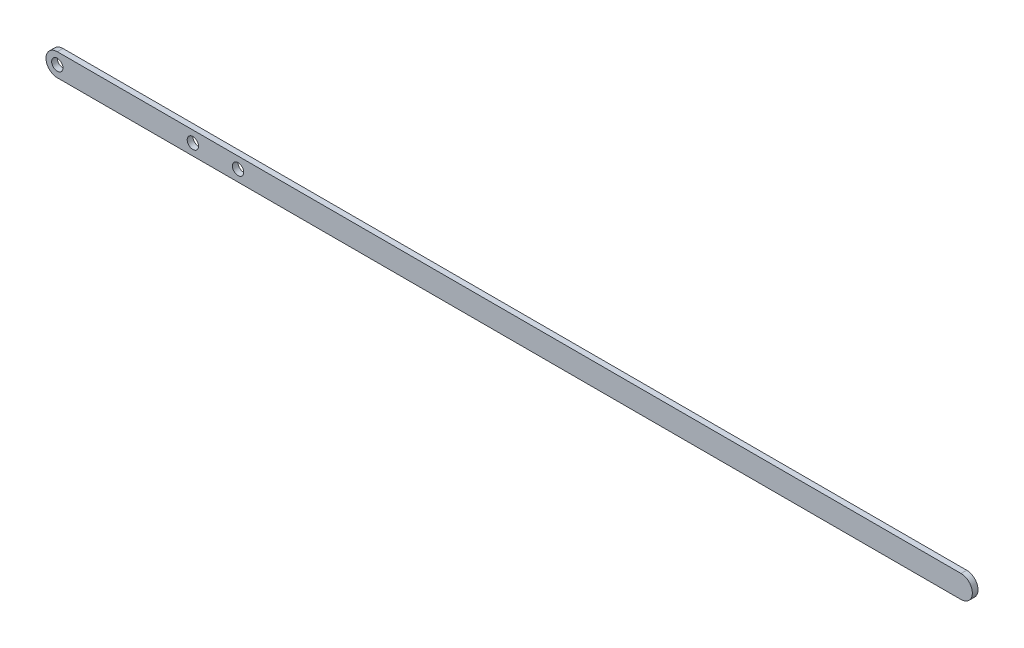
from build123d import *

# Parameters (mm, degrees)
SKETCH1_R           = 3.175
BOSS_EXTRUDE2_DEPTH = 3.175


with BuildPart() as part:
    # Sketch1 → Boss-Extrude2 (new body)
    with BuildSketch(Plane.XY):
        with BuildLine():
            Line((-254, 6.35), (254, 6.35))
            ThreePointArc((254, 6.35), (260.35, 0), (254, -6.35))
            Line((254, -6.35), (-254, -6.35))
            ThreePointArc((-254, -6.35), (-260.35, 0), (-254, 6.35))
        make_face()
        with Locations((-254, 0)):
            Circle(SKETCH1_R, mode=Mode.SUBTRACT)
        with Locations((-177.8, 0)):
            Circle(SKETCH1_R, mode=Mode.SUBTRACT)
        with Locations((-152.4, 0)):
            Circle(SKETCH1_R, mode=Mode.SUBTRACT)
    extrude(amount=BOSS_EXTRUDE2_DEPTH)


solid = part.part
